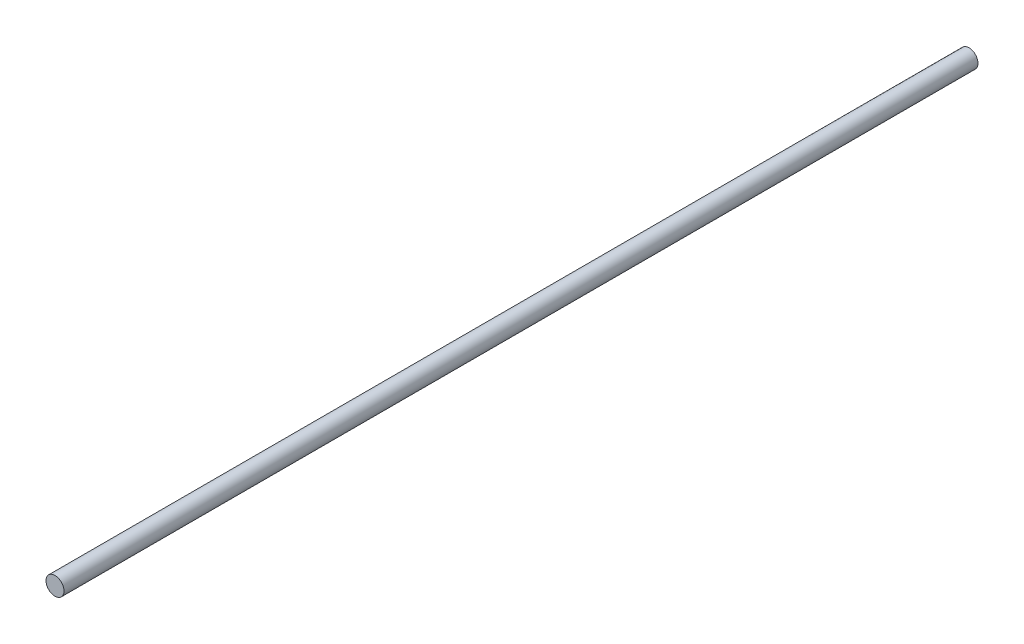
from build123d import *

# Parameters (mm, degrees)
IZIM1_R                     = 6
Y_KSEKLIK_EKSTR_ZYON1_DEPTH = 609


with BuildPart() as part:
    # Çizim1 → Yükseklik-Ekstrüzyon1 (new body)
    with BuildSketch(Plane.XY):
        Circle(IZIM1_R)
    extrude(amount=Y_KSEKLIK_EKSTR_ZYON1_DEPTH)


solid = part.part
